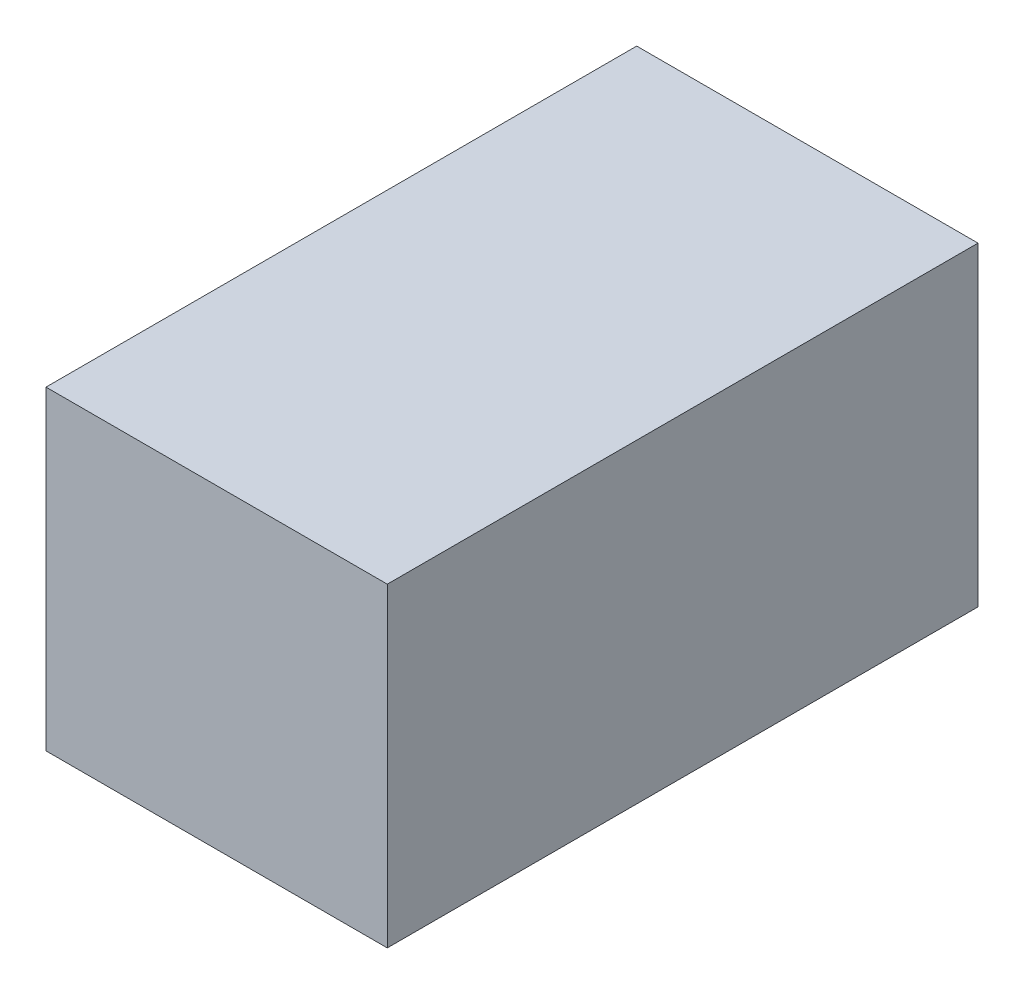
from build123d import *

# Parameters (mm, degrees)
SKETCH2_W           = 26
SKETCH2_H           = 45
BOSS_EXTRUDE1_DEPTH = 12


with BuildPart() as part:
    # Sketch2 → Boss-Extrude1 (new body, symmetric)
    with BuildSketch(Plane(origin=(0, 0, 0), x_dir=(1, 0, 0), z_dir=(0, 1, 0))):
        Rectangle(SKETCH2_W, SKETCH2_H)
    extrude(amount=BOSS_EXTRUDE1_DEPTH, both=True)


solid = part.part
